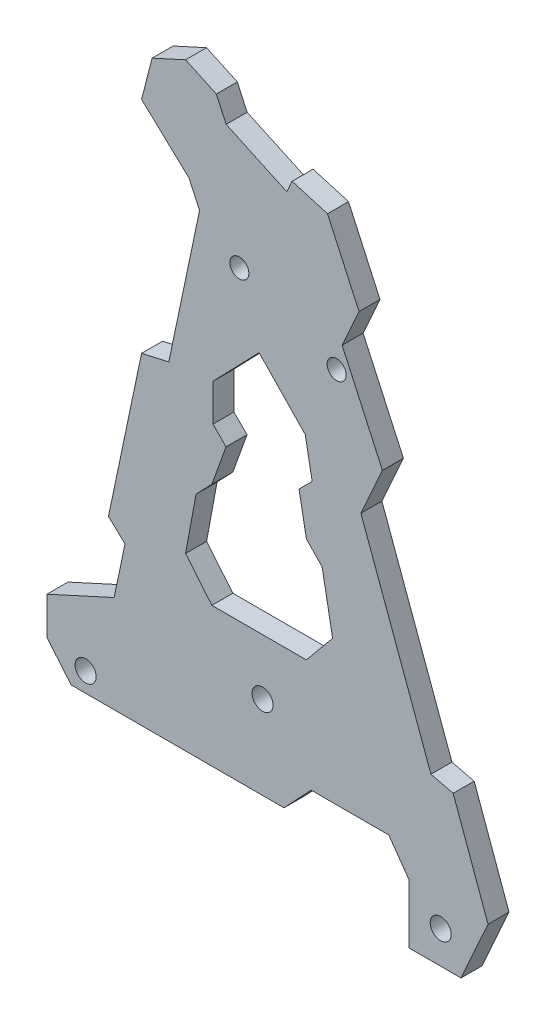
from build123d import *

# Parameters (mm, degrees)
SKETCH1_R           = 1
SKETCH1_R_2         = 0.910218414
SKETCH1_R_3         = 0.906034418
BOSS_EXTRUDE1_DEPTH = 2


with BuildPart() as part:
    # Sketch1 → Boss-Extrude1 (new body)
    with BuildSketch(Plane.XY):
        Polygon((-20.265114669, -14.781853255), (0, -14.781853255), (2.578230219, -12.031741021), (9.974883423, -12.031741021), (11.921608737, -14.781853255), (11.921608737, -20.387219314), (16.856252033, -20.387219314), (19.428429521, -14.668134436), (16.109635951, -5.526454973), (13.99339942, -5.01215501), (7.32119149, 13.172265413), (9.371469902, 17.730938487), (5.533408169, 26.134970212), (7.143643167, 29.715232721), (4.143999648, 36.283417669), (0.771614698, 37.274543445), (0.269863196, 36.158928585), (-5.511384257, 38.825843561), (-6.442002374, 40.863576334), (-9.378393977, 42.218146745), (-12.56174706, 40.764331952), (-13.563489591, 36.865253111), (-9.034751731, 32.619561367), (-8.044765523, 30.451832945), (-10.970070519, 16.504069812), (-13.563489591, 15.919840508), (-16.715889982, 0.889293603), (-15.139689787, -0.58839408), (-16.175363684, -5.526454973), (-22.571570479, -8.447557289), (-22.571570479, -12.031741021), align=None)
        with Locations((-18.892731675, -12.928934576)):
            Circle(SKETCH1_R, mode=Mode.SUBTRACT)
        with Locations((14.921608737, -17.281853255)):
            Circle(SKETCH1_R, mode=Mode.SUBTRACT)
        with Locations((-2.044247077, -6.842384565)):
            Circle(SKETCH1_R, mode=Mode.SUBTRACT)
        with Locations((5.01567612, 23.865741995)):
            Circle(SKETCH1_R_2, mode=Mode.SUBTRACT)
        with Locations((-4.254696048, 27.615435298)):
            Circle(SKETCH1_R_3, mode=Mode.SUBTRACT)
        Polygon((2.128672216, -1.518848285), (-6.871327784, -1.518848285), (-9.371327784, 1.510447631), (-8.371327784, 6.908565954), (-6.871327784, 8.46349525), (-5.519746073, 12.22825254), (-6.7697323, 13.478238768), (-6.7697323, 17.009479478), (-2.371327784, 21.568951505), (2.027076733, 17.009479478), (2.681238146, 13.478238768), (1.431251918, 12.22825254), (2.128672216, 8.46349525), (3.628672216, 6.908565954), (4.628672216, 1.510447631), align=None, mode=Mode.SUBTRACT)
    extrude(amount=BOSS_EXTRUDE1_DEPTH)


solid = part.part
